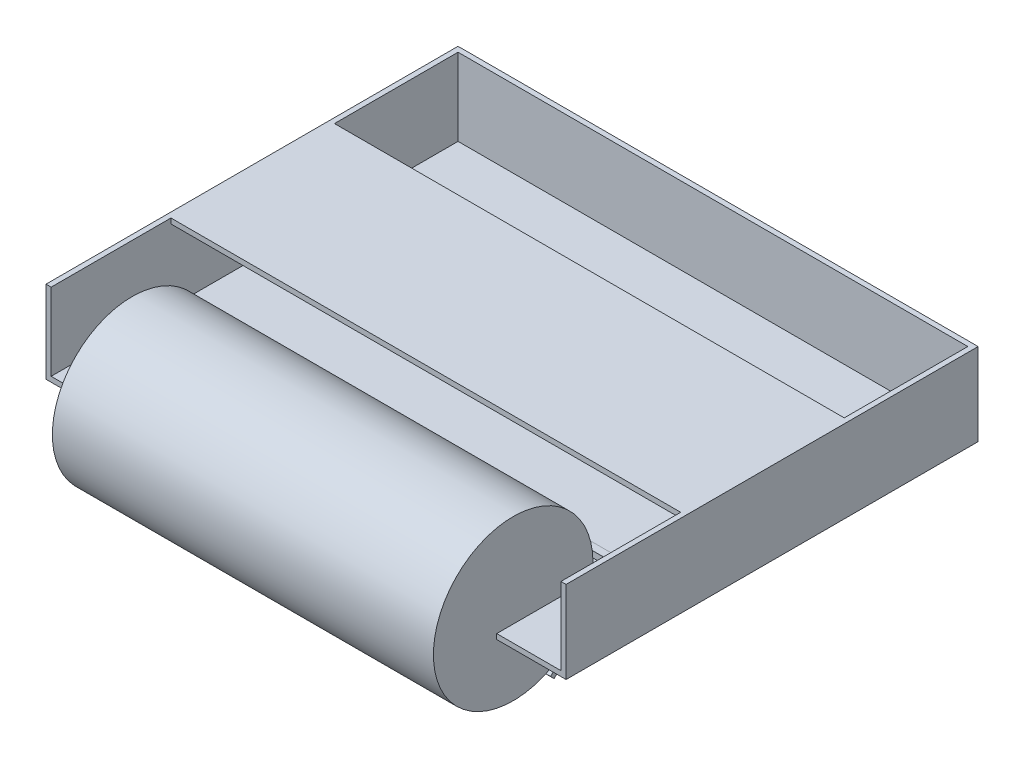
from build123d import *

# Parameters (mm, degrees)
SKETCH1_W                = 5
SKETCH1_H                = 400
BOSS_EXTRUDE1_DEPTH      = 80
SKETCH10_W               = 500
SKETCH10_H               = 5
BOSS_EXTRUDE5_DEPTH      = 80
SKETCH11_W               = 495
SKETCH11_H               = 395.112751059
BOSS_EXTRUDE6_DEPTH      = 5
EXTRUDE_THIN1_DEPTH      = 190
EXTRUDE_THIN1_DEPTH_BACK = 313.159542249
BODY_MOVE_COPY4_ANGLE    = 10
BODY_MOVE_COPY5_ANGLE    = 10
SKETCH15_W               = 495
SKETCH15_H               = 37.5
CUT_EXTRUDE2_DEPTH       = 96
CUT_EXTRUDE2_DEPTH_BACK  = 22
SKETCH17_W               = 370
SKETCH17_H               = 200
CUT_EXTRUDE4_DEPTH       = 53
CUT_EXTRUDE4_DEPTH_BACK  = 1
SKETCH13_R               = 77.5
BOSS_EXTRUDE8_DEPTH      = 370
SKETCH20_W               = 66.837166952
SKETCH20_H               = 67.820860671
CUT_EXTRUDE7_DEPTH       = 229
SKETCH21_W               = 73.786892105
SKETCH21_H               = 71.506175243
CUT_EXTRUDE13_DEPTH      = 266
SKETCH22_W               = 495
SKETCH22_H               = 5
BOSS_EXTRUDE11_DEPTH     = 80
BOSS_EXTRUDE12_START     = 75
SKETCH24_W               = 495
SKETCH24_H               = 153.796031466
BOSS_EXTRUDE12_DEPTH     = 5


with BuildPart() as part:
    # Sketch1 → Boss-Extrude1 (new body)
    with BuildSketch(Plane(origin=(0, 0, 0), x_dir=(1, 0, 0), z_dir=(0, 1, 0))):
        with Locations((-311.765847089, 0)):
            Rectangle(SKETCH1_W, SKETCH1_H)
    extrude(amount=BOSS_EXTRUDE1_DEPTH)


with BuildPart() as body_2:
    # Body-Move/Copy2: copy of part
    add(part.part.moved(Location((500, 0, 0))))


with BuildPart() as body_3:
    # Sketch10 → Boss-Extrude5 (new body)
    with BuildSketch(Plane(origin=(-22.341315564, 0, 0), x_dir=(1, 0, 0), z_dir=(0, 1, 0))):
        with Locations((-38.382537798, 197.612751059)):
            Rectangle(SKETCH10_W, SKETCH10_H)
    extrude(amount=BOSS_EXTRUDE5_DEPTH)


with BuildPart() as part_1:
    add(part.part)

    add(body_2.part)  # Boss-Extrude6 merges body 2

    add(body_3.part)  # Boss-Extrude6 merges body 3
    # Sketch11 → Boss-Extrude6 (add)
    with BuildSketch(Plane(origin=(0, 0, 0), x_dir=(1, 0, 0), z_dir=(0, 1, 0))):
        with Locations((-61.765847089, -2.44362447)):
            Rectangle(SKETCH11_W, SKETCH11_H)
    extrude(amount=BOSS_EXTRUDE6_DEPTH)


with BuildPart() as body_2_2:
    # Sketch12 → Extrude-Thin1 (new body, two sides)
    with BuildSketch(Plane(origin=(0, 8.786754427, -129.055455641), x_dir=(0, 0, -1), z_dir=(1, 0, 0))) as extrude_thin1_sk:
        Polygon((-330, -65), (-200, -6.818515687), (-197.967896543, -11.359022904), (-327.967896543, -69.540507217), align=None)
    extrude(amount=EXTRUDE_THIN1_DEPTH)
    extrude(extrude_thin1_sk.sketch, amount=-EXTRUDE_THIN1_DEPTH_BACK)


with BuildPart() as body_2_2_1:
    # Body-Move/Copy4: moved
    add(body_2_2.part.rotate(Axis((0, -29.392757026, 134.928492631), (1, 0, 0)), BODY_MOVE_COPY4_ANGLE))


with BuildPart() as body_2_2_2:
    # Body-Move/Copy5: moved
    add(body_2_2_1.part.rotate(Axis((0, -29.392757026, 134.928492631), (1, 0, 0)), BODY_MOVE_COPY5_ANGLE))


with BuildPart() as body_2_2_3:
    # Body-Move/Copy6: moved
    add(body_2_2_2.part.moved(Location((0, 20.013956544, -39.986468362))))

    # Sketch15 → Cut-Extrude2 (cut, two sides)
    with BuildSketch(Plane.XY) as cut_extrude2_sk:
        with Locations((-61.765847089, 23.75)):
            Rectangle(SKETCH15_W, SKETCH15_H)
    extrude(amount=CUT_EXTRUDE2_DEPTH, mode=Mode.SUBTRACT)
    extrude(cut_extrude2_sk.sketch, amount=-CUT_EXTRUDE2_DEPTH_BACK, mode=Mode.SUBTRACT)


with BuildPart() as cut_extrude4_tool:
    # Sketch17 → Cut-Extrude4 (new body, two sides)
    with BuildSketch(Plane(origin=(0, 0, 0), x_dir=(1, 0, 0), z_dir=(0, 1, 0))) as cut_extrude4_sk:
        with Locations((-61.590575193, -183.731937495)):
            Rectangle(SKETCH17_W, SKETCH17_H)
    extrude(amount=CUT_EXTRUDE4_DEPTH)
    extrude(cut_extrude4_sk.sketch, amount=-CUT_EXTRUDE4_DEPTH_BACK)


with BuildPart() as part_2:
    add(part_1.part)

    # Cut-Extrude4: cut by cut_extrude4_tool
    add(cut_extrude4_tool.part, mode=Mode.SUBTRACT)

    # Sketch22 → Boss-Extrude11 (add)
    with BuildSketch(Plane(origin=(0, 0, 0), x_dir=(1, 0, 0), z_dir=(0, 1, 0))):
        with Locations((-61.765847089, 72.612751059)):
            Rectangle(SKETCH22_W, SKETCH22_H)
    extrude(amount=BOSS_EXTRUDE11_DEPTH)

    # Sketch24 → Boss-Extrude12 (add)
    with BuildSketch(Plane(origin=(0, 0, 0), x_dir=(1, 0, 0), z_dir=(0, 1, 0)).offset(BOSS_EXTRUDE12_START)):
        with Locations((-61.765847089, -6.785264674)):
            Rectangle(SKETCH24_W, SKETCH24_H)
    extrude(amount=BOSS_EXTRUDE12_DEPTH)


with BuildPart() as body_2_2_4:
    add(body_2_2_3.part)

    # Cut-Extrude4: cut by cut_extrude4_tool
    add(cut_extrude4_tool.part, mode=Mode.SUBTRACT)

    # Sketch20 → Cut-Extrude7 (cut)
    with BuildSketch(Plane.XY):
        with Locations((-279.740958773, -33.910430336)):
            Rectangle(SKETCH20_W, SKETCH20_H)
    extrude(amount=CUT_EXTRUDE7_DEPTH, mode=Mode.SUBTRACT)

    # Sketch21 → Cut-Extrude13 (cut)
    with BuildSketch(Plane.XY):
        with Locations((160.30287086, -35.753087622)):
            Rectangle(SKETCH21_W, SKETCH21_H)
    extrude(amount=CUT_EXTRUDE13_DEPTH, mode=Mode.SUBTRACT)


with BuildPart() as body_3_2:
    # Sketch13 → Boss-Extrude8 (new body)
    with BuildSketch(Plane(origin=(0, 0, 122.437558473), x_dir=(0, 0, -1), z_dir=(1, 0, 0))):
        with Locations((-176.536421204, 16.838724101)):
            Circle(SKETCH13_R)
    extrude(amount=BOSS_EXTRUDE8_DEPTH)


with BuildPart() as body_3_2_1:
    # Body-Move/Copy9: moved
    add(body_3_2.part.moved(Location((-247.702651454, 0, -116.094313443))))


solid = Compound([part_2.part, body_2_2_4.part, body_3_2_1.part])
